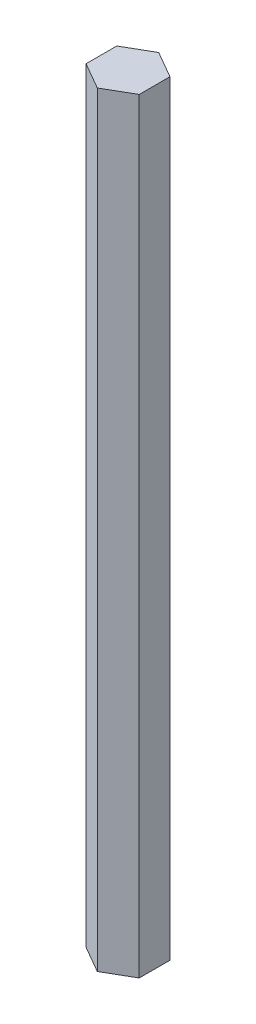
from build123d import *

# Parameters (mm, degrees)
BOSS_EXTRUDE1_DEPTH = 151.892
CUT_EXTRUDE1_DEPTH  = 10.16


with BuildPart() as part:
    # Sketch1 → Boss-Extrude1 (new body)
    # profile 1 of 2: a face of its own
    with BuildSketch(Plane(origin=(0, 0, 0), x_dir=(1, 0, 0), z_dir=(0, 1, 0))):
        Polygon((0, 6.096), (-5.279290861, 3.048), (-5.279290861, -3.048), (0, -6.096), (5.279290861, -3.048), (5.279290861, 3.048), align=None)
        with BuildLine():
            ThreePointArc((2, 1.858932557), (-2.7305, 0), (2, -1.858932557))
            Line((2, -1.858932557), (2, 1.858932557))
        make_face(mode=Mode.SUBTRACT)
    # profile 2 of 2: a face of its own
    with BuildSketch(Plane(origin=(0, 0, 0), x_dir=(1, 0, 0), z_dir=(0, 1, 0))):
        with BuildLine():
            Line((2, -1.858932557), (2, 1.858932557))
            ThreePointArc((2, 1.858932557), (-2.7305, 0), (2, -1.858932557))
        make_face()
    extrude(amount=BOSS_EXTRUDE1_DEPTH)

    # Sketch1_3 → Cut-Extrude1 (cut)
    with BuildSketch(Plane(origin=(0, 0, 0), x_dir=(1, 0, 0), z_dir=(0, 1, 0))):
        with BuildLine():
            Line((2, -1.858932557), (2, 1.858932557))
            ThreePointArc((2, 1.858932557), (-2.7305, 0), (2, -1.858932557))
        make_face()
    extrude(amount=CUT_EXTRUDE1_DEPTH, mode=Mode.SUBTRACT)


solid = part.part
